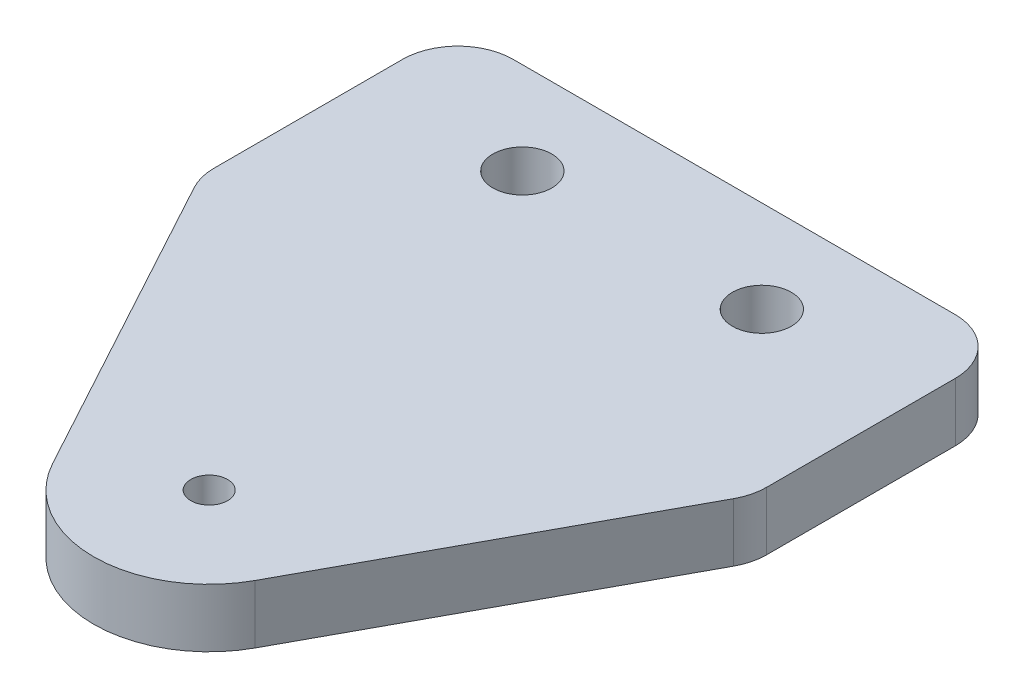
from build123d import *

# Parameters (mm, degrees)
SKETCH1_W           = 30
SKETCH1_H           = 35
SKETCH1_R           = 1.6
BOSS_EXTRUDE1_DEPTH = 3.175
CUT_EXTRUDE1_REACH  = 5.175
SKETCH2_R           = 1
CUT_EXTRUDE2_DEPTH  = 4.175
FILLET1_R           = 3


with BuildPart() as part:
    # Sketch1 → Boss-Extrude1 (new body)
    with BuildSketch(Plane(origin=(0, 0, 0), x_dir=(1, 0, 0), z_dir=(0, 1, 0))):
        with Locations((6.5, -12.5)):
            Rectangle(SKETCH1_W, SKETCH1_H)
        Circle(SKETCH1_R, mode=Mode.SUBTRACT)
        with Locations((13, 0)):
            Circle(SKETCH1_R, mode=Mode.SUBTRACT)
    extrude(amount=BOSS_EXTRUDE1_DEPTH)

    # Sketch2 → Cut-Extrude1 (cut, up to next)
    with BuildSketch(Plane(origin=(0, 3.175, 0), x_dir=(1, 0, 0), z_dir=(0, 1, 0)), mode=Mode.PRIVATE) as cut_extrude1_sk1:
        with Locations((6.5, -23.5)):
            Circle(SKETCH2_R)
    cut_extrude1_tool1 = extrude(cut_extrude1_sk1.sketch, amount=-CUT_EXTRUDE1_REACH, mode=Mode.PRIVATE) & part.part
    add(cut_extrude1_tool1.solids().sort_by_distance((6.5, 3.175, 23.5))[0], mode=Mode.SUBTRACT)

    # Sketch3 → Cut-Extrude2 (cut, through all)
    with BuildSketch(Plane(origin=(0, 3.175, 0), x_dir=(1, 0, 0), z_dir=(0, 1, 0))):
        with BuildLine():
            Line((21.5, -9), (11.998845434, -26.5))
            ThreePointArc((11.998845434, -26.5), (6.5, -29.771562929), (1.001154566, -26.5))
            Line((1.001154566, -26.5), (-8.5, -9))
            Line((-8.5, -9), (-8.5, -30))
            Line((-8.5, -30), (21.5, -30))
            Line((21.5, -30), (21.5, -9))
        make_face()
    extrude(amount=-CUT_EXTRUDE2_DEPTH, mode=Mode.SUBTRACT)

    # Fillet1
    fillet1_edges = [part.edges().sort_by_distance(p)[0] for p in [
        (21.5, 1.5875, 9),
        (-8.5, 1.5875, 9),
        (-8.5, 1.5875, -5),
        (21.5, 1.5875, -5),
    ]]
    fillet(fillet1_edges, radius=FILLET1_R)


solid = part.part
